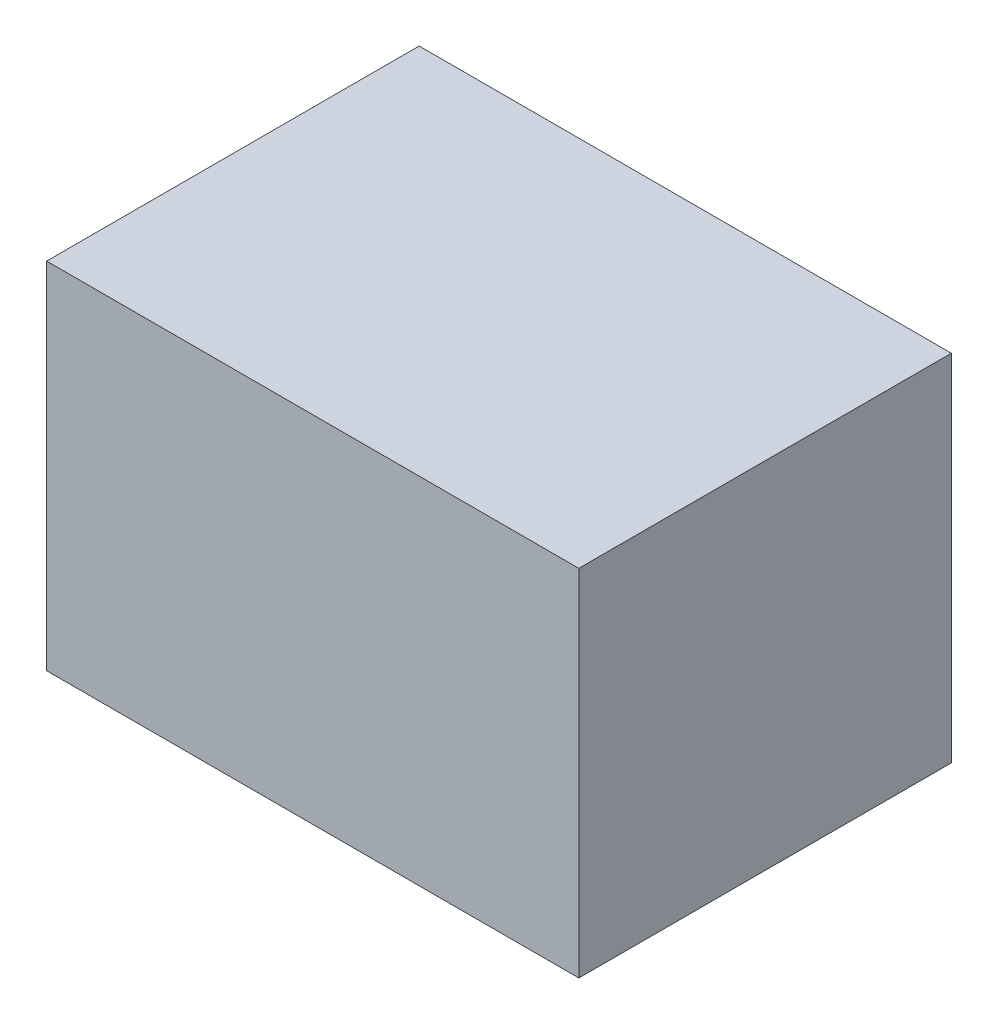
from build123d import *

# Parameters (mm, degrees)
SKETCH1_W                = 152.4
SKETCH1_H                = 101.6
BOSS_EXTRUDE1_DEPTH      = 101.6
BOSS_EXTRUDE1_DEPTH_BACK = 5.08
SKETCH2_R                = 12.954
CUT_EXTRUDE1_DEPTH       = 101.6


with BuildPart() as part:
    # Sketch1 → Boss-Extrude1 (new body, two sides)
    with BuildSketch(Plane.XY) as boss_extrude1_sk:
        with Locations((76.2, 50.8)):
            Rectangle(SKETCH1_W, SKETCH1_H)
    extrude(amount=BOSS_EXTRUDE1_DEPTH)
    extrude(boss_extrude1_sk.sketch, amount=-BOSS_EXTRUDE1_DEPTH_BACK)

    # Sketch2 → Cut-Extrude1 (cut)
    with BuildSketch(Plane(origin=(0, 0, -5.08), x_dir=(-1, 0, 0), z_dir=(0, 0, -1))):
        with Locations((-76.2, 50.8)):
            Circle(SKETCH2_R)
    extrude(amount=-CUT_EXTRUDE1_DEPTH, mode=Mode.SUBTRACT)


solid = part.part
